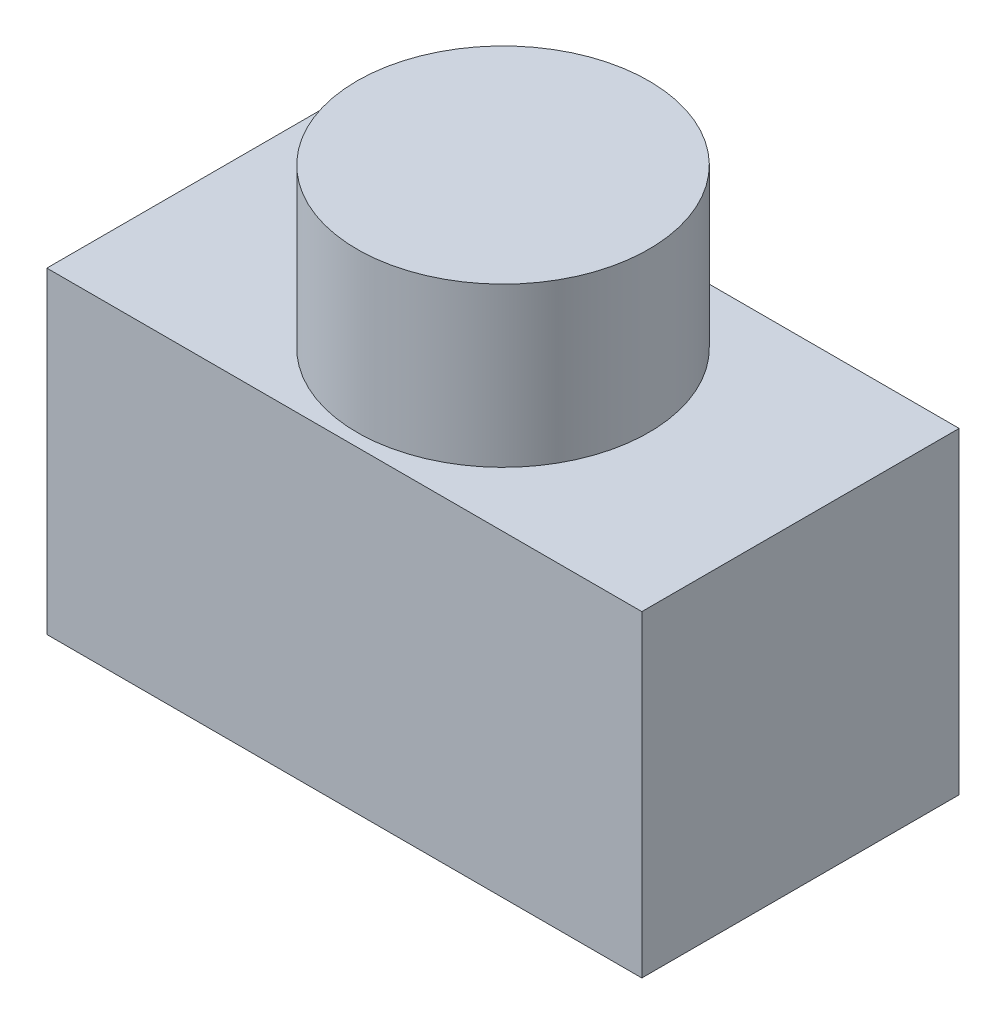
from build123d import *

# Parameters (mm, degrees)
SKIZZE1_W                          = 75
SKIZZE1_H                          = 40
AUFSATZ_LINEAR_AUSTRAGEN1_DEPTH    = 40
SKIZZE2_R                          = 18.39
AUFSATZ_LINEAR_AUSTRAGEN2_DEPTH    = 20
K_RPER_VERSCHIEBEN_KOPIEREN1_ANGLE = 180
K_RPER_VERSCHIEBEN_KOPIEREN2_ANGLE = 90
K_RPER_VERSCHIEBEN_KOPIEREN3_ANGLE = 180


with BuildPart() as part:
    # Skizze1 → Aufsatz-Linear austragen1 (new body)
    with BuildSketch(Plane.XY):
        Rectangle(SKIZZE1_W, SKIZZE1_H)
    extrude(amount=AUFSATZ_LINEAR_AUSTRAGEN1_DEPTH)

    # Skizze2 → Aufsatz-Linear austragen2 (add)
    with BuildSketch(Plane(origin=(0, 0, 0), x_dir=(-1, 0, 0), z_dir=(0, 0, -1))):
        Circle(SKIZZE2_R)
    extrude(amount=AUFSATZ_LINEAR_AUSTRAGEN2_DEPTH)


with BuildPart() as part_1:
    # Körper-Verschieben/Kopieren1: moved
    add(part.part.rotate(Axis((0, 0, 10), (1, 0, 0)), K_RPER_VERSCHIEBEN_KOPIEREN1_ANGLE))


with BuildPart() as part_2:
    # Körper-Verschieben/Kopieren2: moved
    add(part_1.part.rotate(Axis((0, 0, 10), (1, 0, 0)), K_RPER_VERSCHIEBEN_KOPIEREN2_ANGLE))


with BuildPart() as part_3:
    # Körper-Verschieben/Kopieren3: moved
    add(part_2.part.rotate(Axis((0, 0, 10), (1, 0, 0)), K_RPER_VERSCHIEBEN_KOPIEREN3_ANGLE))


with BuildPart() as part_4:
    # Körper-Verschieben/Kopieren4: moved
    add(part_3.part.moved(Location((0, -10, 0))))


with BuildPart() as part_5:
    # Körper-Verschieben/Kopieren5: moved
    add(part_4.part.moved(Location((0, 0, -10))))


solid = part_5.part
